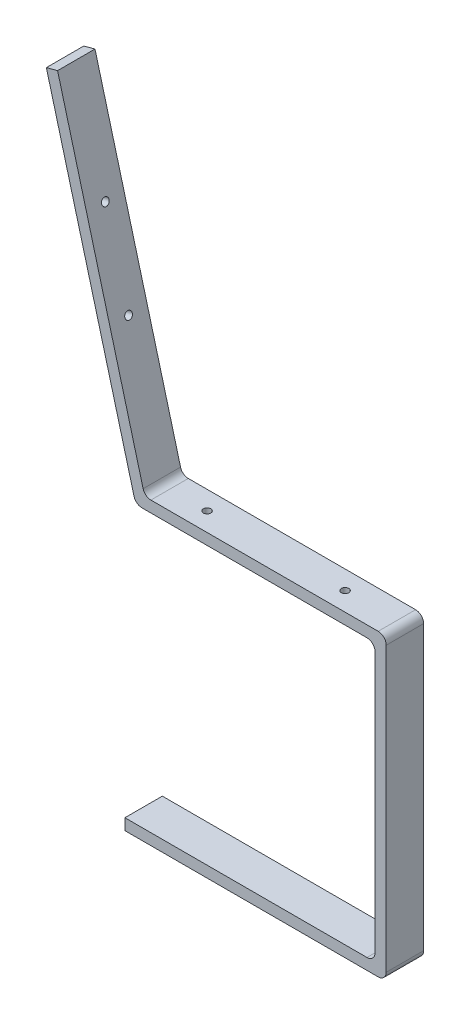
from build123d import *

# Parameters (mm, degrees)
BOSS_EXTRUDE1_DEPTH = 25
SKETCH3_R           = 5
CUT_EXTRUDE1_DEPTH  = 20
SKETCH2_R           = 5
CUT_EXTRUDE2_DEPTH  = 20


with BuildPart() as part:
    # Sketch1 → Boss-Extrude1 (new body, symmetric)
    with BuildSketch(Plane.XY):
        with BuildLine():
            Line((-388.398049097, -14.110780444), (-502.733667869, 412.59555793))
            Line((-502.733667869, 412.59555793), (-517.733667869, 408.576320044))
            Line((-517.733667869, 408.576320044), (-400.48638755, -29.110107171))
            ThreePointArc((-400.48638755, -29.110107171), (-396.65053803, -34.851466611), (-390.112163796, -37.0710639))
            Line((-390.112163796, -37.0710639), (-89.247234395, -37.0710639))
            ThreePointArc((-89.247234395, -37.0710639), (-81.652907565, -40.21673707), (-78.507234395, -47.8110639))
            Line((-78.507234395, -47.8110639), (-78.507234395, -396.3310639))
            ThreePointArc((-78.507234395, -396.3310639), (-81.652907565, -403.92539073), (-89.247234395, -407.0710639))
            Line((-89.247234395, -407.0710639), (-412.734449588, -407.0710639))
            Line((-412.734449588, -407.0710639), (-412.734449588, -422.0710639))
            Line((-412.734449588, -422.0710639), (-74.247234395, -422.0710639))
            ThreePointArc((-74.247234395, -422.0710639), (-66.652907565, -418.92539073), (-63.507234395, -411.3310639))
            Line((-63.507234395, -411.3310639), (-63.507234395, -32.8110639))
            ThreePointArc((-63.507234395, -32.8110639), (-66.652907565, -25.21673707), (-74.247234395, -22.0710639))
            Line((-74.247234395, -22.0710639), (-378.024005722, -22.0710639))
            ThreePointArc((-378.024005722, -22.0710639), (-384.56210347, -19.851678775), (-388.398049097, -14.110780444))
        make_face()
    extrude(amount=BOSS_EXTRUDE1_DEPTH, both=True)

    # Sketch3 → Cut-Extrude1 (cut)
    with BuildSketch(Plane(origin=(0, -22.0710639, 0), x_dir=(1, 0, 0), z_dir=(0, 1, 0))):
        with Locations((-327.977212353, 0)):
            Circle(SKETCH3_R)
        with Locations((-143.507234395, 0)):
            Circle(SKETCH3_R)
    extrude(amount=-CUT_EXTRUDE1_DEPTH, mode=Mode.SUBTRACT)

    # Sketch2 → Cut-Extrude2 (cut)
    with BuildSketch(Plane(origin=(-365.908008308, -98.04475533, 0), x_dir=(0, 0, -1), z_dir=(0.965925826, 0.258819045, 0))):
        with Locations((0, 378.653753076)):
            Circle(SKETCH2_R)
        with Locations((0, 258.653753076)):
            Circle(SKETCH2_R)
    extrude(amount=-CUT_EXTRUDE2_DEPTH, mode=Mode.SUBTRACT)


solid = part.part
